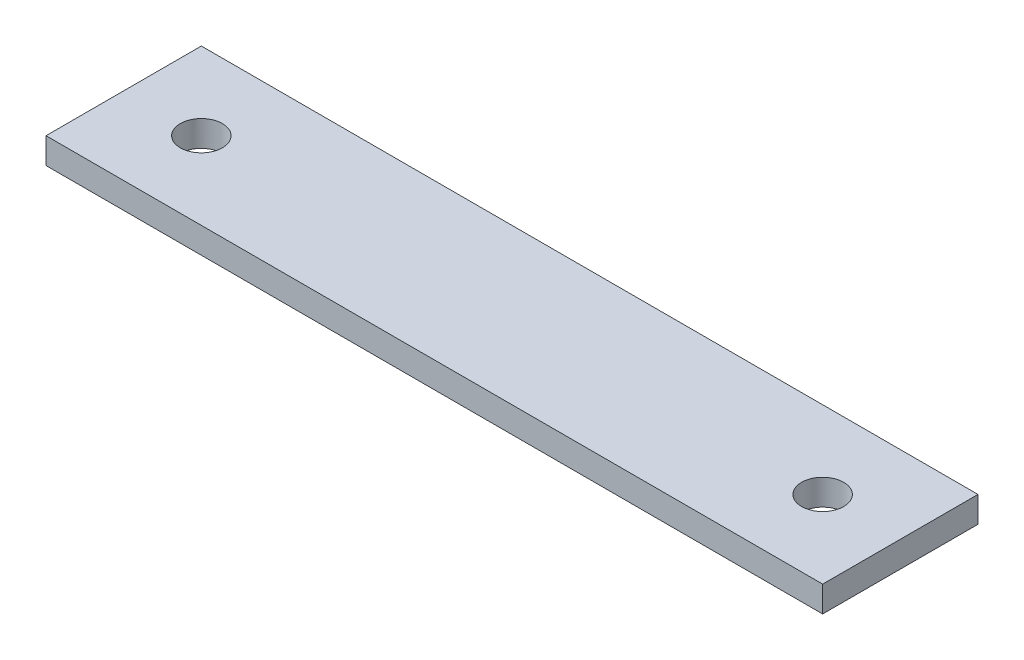
from build123d import *

# Parameters (mm, degrees)
SKETCH1_W           = 381
SKETCH1_H           = 76.2
BOSS_EXTRUDE1_DEPTH = 12.7
CUT_EXTRUDE1_REACH  = 14.7
SKETCH2_R           = 10.31875


with BuildPart() as part:
    # Sketch1 → Boss-Extrude1 (new body)
    with BuildSketch(Plane(origin=(0, 0, 0), x_dir=(1, 0, 0), z_dir=(0, 1, 0))):
        with Locations((190.5, 38.1)):
            Rectangle(SKETCH1_W, SKETCH1_H)
    extrude(amount=BOSS_EXTRUDE1_DEPTH)

    # Sketch2 → Cut-Extrude1 (cut, up to next)
    with BuildSketch(Plane(origin=(0, 12.7, 0), x_dir=(1, 0, 0), z_dir=(0, 1, 0)), mode=Mode.PRIVATE) as cut_extrude1_sk1:
        with Locations((38.1, 38.1)):
            Circle(SKETCH2_R)
    cut_extrude1_tool1 = extrude(cut_extrude1_sk1.sketch, amount=-CUT_EXTRUDE1_REACH, mode=Mode.PRIVATE) & part.part
    add(cut_extrude1_tool1.solids().sort_by_distance((38.1, 12.7, -38.1))[0], mode=Mode.SUBTRACT)
    # Sketch2 → Cut-Extrude1 (cut, up to next)
    with BuildSketch(Plane(origin=(0, 12.7, 0), x_dir=(1, 0, 0), z_dir=(0, 1, 0)), mode=Mode.PRIVATE) as cut_extrude1_sk2:
        with Locations((342.9, 38.1)):
            Circle(SKETCH2_R)
    cut_extrude1_tool2 = extrude(cut_extrude1_sk2.sketch, amount=-CUT_EXTRUDE1_REACH, mode=Mode.PRIVATE) & part.part
    add(cut_extrude1_tool2.solids().sort_by_distance((342.9, 12.7, -38.1))[0], mode=Mode.SUBTRACT)


solid = part.part
